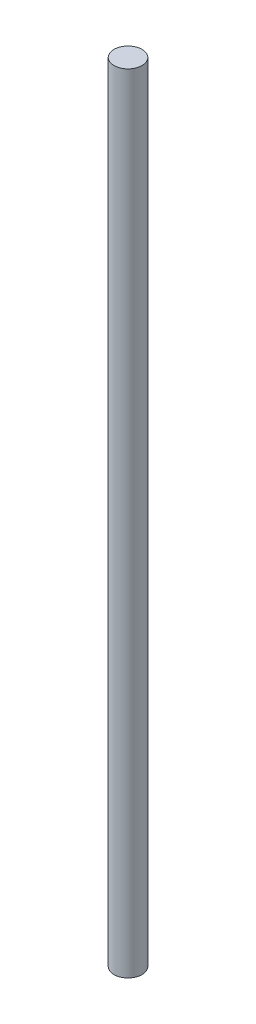
from build123d import *

# Parameters (mm, degrees)
SKETCH1_W = 4.45
SKETCH1_H = 250


with BuildPart() as part:
    # Sketch1 → Revolve1 (revolve)
    with BuildSketch(Plane.XY):
        with Locations((2.225, 79)):
            Rectangle(SKETCH1_W, SKETCH1_H)
    revolve(axis=Axis((0, 204, 0), (0, -1, 0)))


solid = part.part
